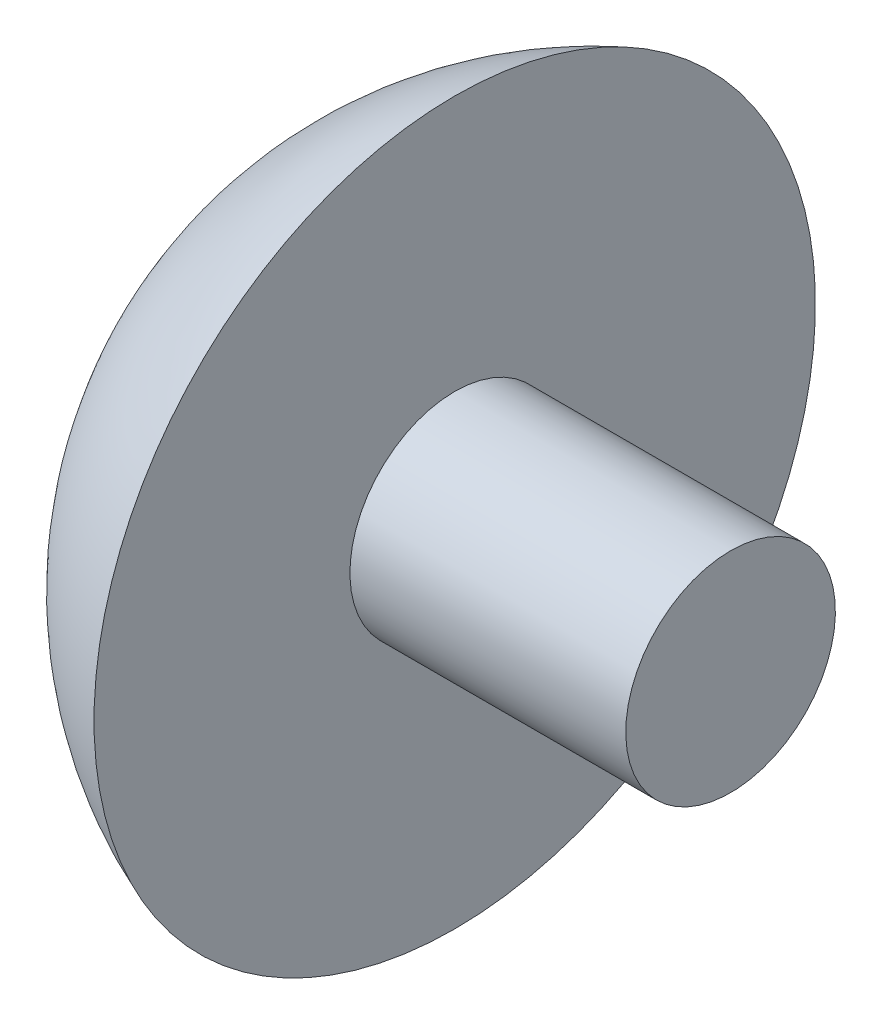
from build123d import *


with BuildPart() as part:
    # Esquisse5 → Révolution2 (revolve)
    with BuildSketch(Plane.XY):
        with BuildLine():
            Line((0, 0), (-9.5, 0))
            ThreePointArc((-9.5, 0), (-8.266281297, -3.968626967), (-5, -6.538348415))
            Line((-5, -6.538348415), (-5, -1.9))
            Line((-5, -1.9), (0, -1.9))
            Line((0, -1.9), (0, 0))
        make_face()
    revolve(axis=Axis((0, 0, 0), (-1, 0, 0)))


solid = part.part
